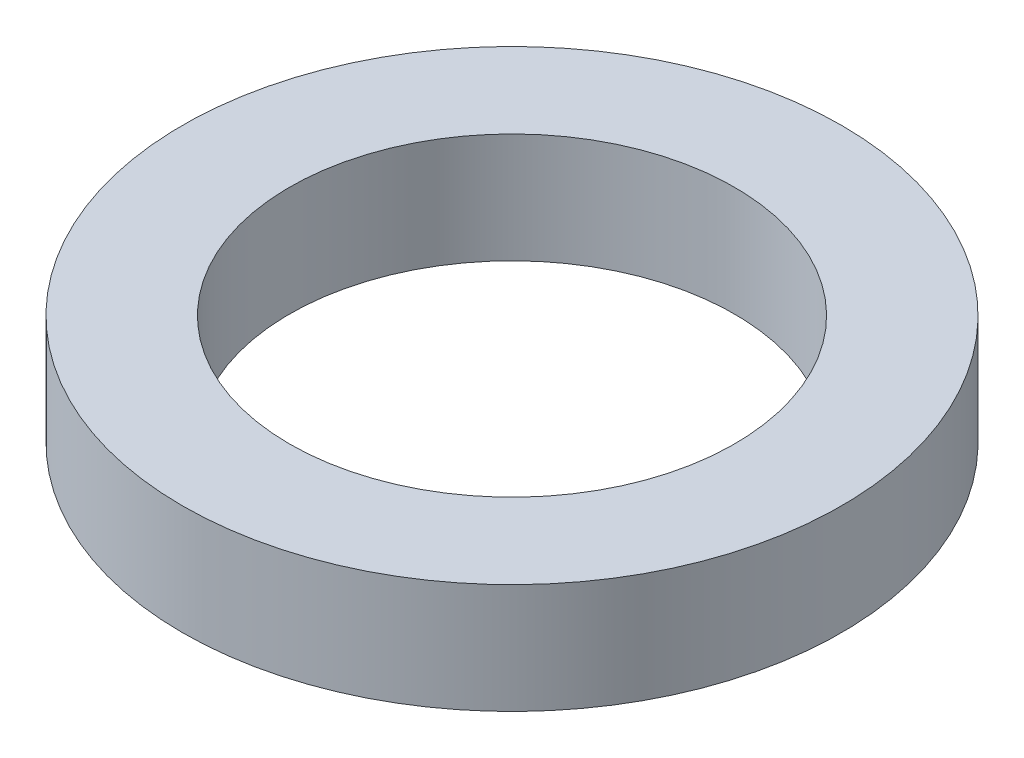
from build123d import *

# Parameters (mm, degrees)
SKETCH1_R           = 6
SKETCH1_R_2         = 4.05
BOSS_EXTRUDE1_DEPTH = 2


with BuildPart() as part:
    # Sketch1 → Boss-Extrude1 (new body)
    with BuildSketch(Plane(origin=(0, 0, 0), x_dir=(1, 0, 0), z_dir=(0, 1, 0))):
        Circle(SKETCH1_R)
        Circle(SKETCH1_R_2, mode=Mode.SUBTRACT)
    extrude(amount=BOSS_EXTRUDE1_DEPTH)


solid = part.part
